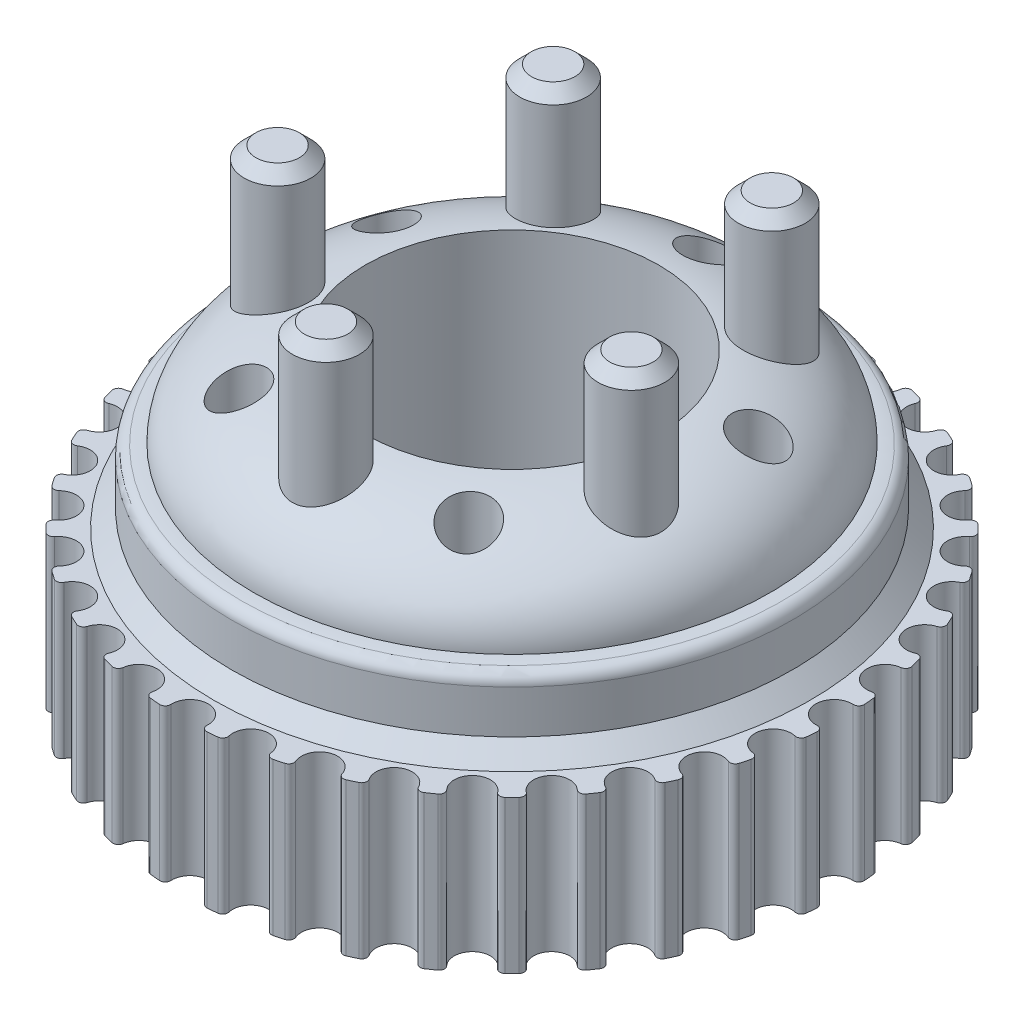
from build123d import *

# Parameters (mm, degrees)
SKIZZE1_R                       = 28.076389757
AUFSATZ_LINEAR_AUSTRAGEN1_DEPTH = 13
SCHNITT_LINEAR_AUSTRAGEN1_DEPTH = 42.779987117
KREISMUSTER1_COUNT              = 36
SKIZZE24_R                      = 12.5
HANGAR_HOLE_DEPTH               = 42.740895817
SKIZZE25_R                      = 2.1
MOUNTING_HOLES_DEPTH            = 42.740895817
MOUNTING_HOLES_DEPTH_BACK       = 42.740895817
SKIZZE28_R                      = 2.85
PINS_DEPTH                      = 10
PINS_DIRECTION_2_REACH          = 49.477
FASE2_SIZE                      = 1
SKIZZE29_R                      = 3.75
COUNTERSINKS_DEPTH              = 5
AUFSATZ_LINEAR_AUSTRAGEN6_DEPTH = 0.4
AUFSATZ_LINEAR_AUSTRAGEN7_DEPTH = 0.2
FASE3_SIZE                      = 1.5
SCHNITT_LINEAR_AUSTRAGEN7_DEPTH = 4.6
KREISMUSTER3_COUNT              = 5


with BuildPart() as part:
    # Skizze1 → Aufsatz-Linear austragen1 (new body)
    with BuildSketch(Plane(origin=(0, 0, 0), x_dir=(1, 0, 0), z_dir=(0, 1, 0))):
        with Locations(Location((0, 0, 0), (0, 0, 90))):
            Circle(SKIZZE1_R)
    extrude(amount=AUFSATZ_LINEAR_AUSTRAGEN1_DEPTH)

    # Zahnung → Schnitt-Linear austragen1 (cut, through all)
    with BuildSketch(Plane(origin=(0, 13, 0), x_dir=(1, 0, 0), z_dir=(0, 1, 0))):
        with BuildLine():
            ThreePointArc((-1.542894139, 27.524912022), (0, 25.892849757), (1.542894139, 27.524912022))
            ThreePointArc((1.542894139, 27.524912022), (1.677698107, 27.873850157), (2.028769929, 28.002995453))
            ThreePointArc((2.028769929, 28.002995453), (0, 28.076389757), (-2.028769929, 28.002995453))
            ThreePointArc((-2.028769929, 28.002995453), (-1.677698107, 27.873850157), (-1.542894139, 27.524912022))
        make_face()
    schnitt_linear_austragen1 = extrude(amount=-SCHNITT_LINEAR_AUSTRAGEN1_DEPTH, mode=Mode.SUBTRACT)

    # Kreismuster1: Schnitt-Linear austragen1 ×36 about axis
    kreismuster1_axis = Axis((0, 0, 0), (0, 1, 0))
    for i in range(1, KREISMUSTER1_COUNT):
        add(schnitt_linear_austragen1.rotate(kreismuster1_axis, i * 360 / KREISMUSTER1_COUNT), mode=Mode.SUBTRACT)

    # Skizze23 → Body (revolve)
    with BuildSketch(Plane(origin=(0, 0, 0), x_dir=(0, 0, -1), z_dir=(1, 0, 0))):
        with BuildLine():
            Line((-23.892849757, 13), (-23.892849757, 18.177651499))
            ThreePointArc((-23.892849757, 18.177651499), (-23.650534927, 18.830271743), (-23.041023393, 19.16661286))
            add(Edge.make_bspline(
                [(-23.041023393, 19.16661286), (-22.705496435, 19.216884035), (-22.359095546, 19.245823161), (-22, 19.25)],
                knots=[0.666203438, 0.666203438, 0.666203438, 0.666203438, 0.739788327, 0.739788327, 0.739788327, 0.739788327], degree=3))
            add(Edge.make_bspline(
                [(-22, 19.25), (-22, 22.881223738), (-18.269694005, 25.679215042), (-12.5, 26.184611956)],
                knots=[0, 0, 0, 0, 0.905796835, 0.905796835, 0.905796835, 0.905796835], degree=3, weights=[1, 0.823132166, 0.806470657, 0.950015471]))
            Line((-12.5, 26.184611956), (-12.5, 13))
            Line((-12.5, 13), (-23.892849757, 13))
        make_face()
    revolve(axis=Axis((0, 13, 0), (0, -1, 0)))

    # Skizze24 → Hangar hole (cut, through all)
    with BuildSketch(Plane(origin=(0, 13, 0), x_dir=(1, 0, 0), z_dir=(0, 1, 0))):
        with Locations(Location((0, 0, 0), (0, 0, 270))):
            Circle(SKIZZE24_R)
    extrude(amount=-HANGAR_HOLE_DEPTH, mode=Mode.SUBTRACT)

    # Skizze25 → Mounting holes (cut, two sides)
    with BuildSketch(Plane(origin=(0, 13, 0), x_dir=(1, 0, 0), z_dir=(0, 1, 0))) as mounting_holes_sk:
        with Locations(Location((0, 16.655, 0), (0, 0, 270))):
            Circle(SKIZZE25_R)
        with Locations(Location((15.839846279, 5.146678041, 0), (0, 0, 270))):
            Circle(SKIZZE25_R)
        with Locations(Location((9.789563377, -13.474178041, 0), (0, 0, 270))):
            Circle(SKIZZE25_R)
        with Locations(Location((-9.789563377, -13.474178041, 0), (0, 0, 270))):
            Circle(SKIZZE25_R)
        with Locations(Location((-15.839846279, 5.146678041, 0), (0, 0, 270))):
            Circle(SKIZZE25_R)
    extrude(amount=MOUNTING_HOLES_DEPTH, mode=Mode.SUBTRACT)
    extrude(mounting_holes_sk.sketch, amount=-MOUNTING_HOLES_DEPTH_BACK, mode=Mode.SUBTRACT)

    # Skizze28 → Pins (add)
    with BuildSketch(Plane(origin=(0, 26.184611956, 0), x_dir=(-1, 0, 0), z_dir=(0, -1, 0))):
        with Locations(Location((-9.316396249, 12.822919361, 0), (0, 0, 270))):
            Circle(SKIZZE28_R)
        with Locations(Location((9.316396249, 12.822919361, 0), (0, 0, 270))):
            Circle(SKIZZE28_R)
        with Locations(Location((15.074245783, -4.897919361, 0), (0, 0, 270))):
            Circle(SKIZZE28_R)
        with Locations(Location((0, -15.85, 0), (0, 0, 90))):
            Circle(SKIZZE28_R)
        with Locations(Location((-15.074245783, -4.897919361, 0), (0, 0, 270))):
            Circle(SKIZZE28_R)
    extrude(amount=-PINS_DEPTH)

    # Skizze28 → Pins direction 2 (add, up to next)
    with BuildSketch(Plane(origin=(0, 26.184611956, 0), x_dir=(-1, 0, 0), z_dir=(0, -1, 0)), mode=Mode.PRIVATE) as pins_direction_2_sk1:
        with Locations(Location((-9.316396249, 12.822919361, 0), (0, 0, 270))):
            Circle(SKIZZE28_R)
    pins_direction_2_tool1 = extrude(pins_direction_2_sk1.sketch, amount=PINS_DIRECTION_2_REACH, mode=Mode.PRIVATE) - part.part
    # Skizze28 → Pins direction 2 (add, up to next)
    with BuildSketch(Plane(origin=(0, 26.184611956, 0), x_dir=(-1, 0, 0), z_dir=(0, -1, 0)), mode=Mode.PRIVATE) as pins_direction_2_sk2:
        with Locations(Location((9.316396249, 12.822919361, 0), (0, 0, 270))):
            Circle(SKIZZE28_R)
    pins_direction_2_tool2 = extrude(pins_direction_2_sk2.sketch, amount=PINS_DIRECTION_2_REACH, mode=Mode.PRIVATE) - part.part
    # Skizze28 → Pins direction 2 (add, up to next)
    with BuildSketch(Plane(origin=(0, 26.184611956, 0), x_dir=(-1, 0, 0), z_dir=(0, -1, 0)), mode=Mode.PRIVATE) as pins_direction_2_sk3:
        with Locations(Location((15.074245783, -4.897919361, 0), (0, 0, 270))):
            Circle(SKIZZE28_R)
    pins_direction_2_tool3 = extrude(pins_direction_2_sk3.sketch, amount=PINS_DIRECTION_2_REACH, mode=Mode.PRIVATE) - part.part
    # Skizze28 → Pins direction 2 (add, up to next)
    with BuildSketch(Plane(origin=(0, 26.184611956, 0), x_dir=(-1, 0, 0), z_dir=(0, -1, 0)), mode=Mode.PRIVATE) as pins_direction_2_sk4:
        with Locations(Location((0, -15.85, 0), (0, 0, 90))):
            Circle(SKIZZE28_R)
    pins_direction_2_tool4 = extrude(pins_direction_2_sk4.sketch, amount=PINS_DIRECTION_2_REACH, mode=Mode.PRIVATE) - part.part
    # Skizze28 → Pins direction 2 (add, up to next)
    with BuildSketch(Plane(origin=(0, 26.184611956, 0), x_dir=(-1, 0, 0), z_dir=(0, -1, 0)), mode=Mode.PRIVATE) as pins_direction_2_sk5:
        with Locations(Location((-15.074245783, -4.897919361, 0), (0, 0, 270))):
            Circle(SKIZZE28_R)
    pins_direction_2_tool5 = extrude(pins_direction_2_sk5.sketch, amount=PINS_DIRECTION_2_REACH, mode=Mode.PRIVATE) - part.part
    add(pins_direction_2_tool1.solids().sort_by_distance((9.316396, 26.184612, -12.822919))[0])
    add(pins_direction_2_tool2.solids().sort_by_distance((-9.316396, 26.184612, -12.822919))[0])
    add(pins_direction_2_tool3.solids().sort_by_distance((-15.074246, 26.184612, 4.897919))[0])
    add(pins_direction_2_tool4.solids().sort_by_distance((0, 26.184612, 15.85))[0])
    add(pins_direction_2_tool5.solids().sort_by_distance((15.074246, 26.184612, 4.897919))[0])

    # Fase2
    fase2_edges = [part.edges().sort_by_distance(p)[0] for p in [
        (9.316396249, 36.184611956, -15.672919361),
        (-9.316396249, 36.184611956, -15.672919361),
        (-15.074245783, 36.184611956, 2.047919361),
        (0, 36.184611956, 18.7),
        (15.074245783, 36.184611956, 2.047919361),
    ]]
    chamfer(fase2_edges, length=FASE2_SIZE)

    # Skizze29 → Countersinks (cut)
    with BuildSketch(Plane.XZ):
        with Locations(Location((-9.789563377, 13.474178041, 0), (0, 0, 270))):
            Circle(SKIZZE29_R)
        with Locations(Location((9.789563377, 13.474178041, 0), (0, 0, 270))):
            Circle(SKIZZE29_R)
        with Locations(Location((15.839846279, -5.146678041, 0), (0, 0, 270))):
            Circle(SKIZZE29_R)
        with Locations(Location((0, -16.655, 0), (0, 0, 270))):
            Circle(SKIZZE29_R)
        with Locations(Location((-15.839846279, -5.146678041, 0), (0, 0, 270))):
            Circle(SKIZZE29_R)
    extrude(amount=-COUNTERSINKS_DEPTH, mode=Mode.SUBTRACT)

    # Skizze32 → Aufsatz-Linear austragen6 (add)
    with BuildSketch(Plane.XZ.offset(-5)):
        with BuildLine():
            Line((7e-09, -14.555), (2.1, -14.555))
            Line((2.1, -14.555), (3.106847277, -14.555))
            ThreePointArc((3.106847277, -14.555), (0, -12.905), (-3.106847277, -14.555))
            Line((-3.106847277, -14.555), (-2.1, -14.555))
            Line((-2.1, -14.555), (7e-09, -14.555))
        make_face()
        with BuildLine():
            Line((3.106847277, -18.755), (2.1, -18.755))
            Line((2.1, -18.755), (0, -18.755))
            Line((0, -18.755), (-2.1, -18.755))
            Line((-2.1, -18.755), (-3.106847277, -18.755))
            ThreePointArc((-3.106847277, -18.755), (0, -20.405), (3.106847277, -18.755))
        make_face()
        with BuildLine():
            Line((-17.939846279, -5.146678041), (-17.939846279, -3.046678041))
            Line((-17.939846279, -3.046678041), (-17.939846279, -2.039830765))
            ThreePointArc((-17.939846279, -2.039830765), (-19.589846279, -5.146678041), (-17.939846279, -8.253525318))
            Line((-17.939846279, -8.253525318), (-17.939846279, -7.246678041))
            Line((-17.939846279, -7.246678041), (-17.939846279, -5.146678041))
        make_face()
        with BuildLine():
            Line((-13.739846279, -2.039830765), (-13.739846279, -3.046678041))
            Line((-13.739846279, -3.046678041), (-13.739846279, -5.146678041))
            Line((-13.739846279, -5.146678041), (-13.739846279, -7.246678041))
            Line((-13.739846279, -7.246678041), (-13.739846279, -8.253525318))
            ThreePointArc((-13.739846279, -8.253525318), (-12.527935954, -6.905583951), (-12.089846279, -5.146678041))
            ThreePointArc((-12.089846279, -5.146678041), (-12.527935954, -3.387772131), (-13.739846279, -2.039830765))
        make_face()
        with BuildLine():
            Line((-12.896410654, 15.574178041), (-11.889563377, 15.574178041))
            Line((-11.889563377, 15.574178041), (-9.789563377, 15.574178041))
            Line((-9.789563377, 15.574178041), (-7.689563377, 15.574178041))
            Line((-7.689563377, 15.574178041), (-6.6827161, 15.574178041))
            ThreePointArc((-6.6827161, 15.574178041), (-9.789563377, 17.224178041), (-12.896410654, 15.574178041))
        make_face()
        with BuildLine():
            Line((-9.789563377, 11.374178041), (-11.889563377, 11.374178041))
            Line((-11.889563377, 11.374178041), (-12.896410654, 11.374178041))
            ThreePointArc((-12.896410654, 11.374178041), (-9.789563377, 9.724178041), (-6.6827161, 11.374178041))
            Line((-6.6827161, 11.374178041), (-7.689563377, 11.374178041))
            Line((-7.689563377, 11.374178041), (-9.789563377, 11.374178041))
        make_face()
        with BuildLine():
            Line((6.6827161, 15.574178041), (7.689563377, 15.574178041))
            Line((7.689563377, 15.574178041), (9.789563377, 15.574178041))
            Line((9.789563377, 15.574178041), (11.889563377, 15.574178041))
            Line((11.889563377, 15.574178041), (12.896410654, 15.574178041))
            ThreePointArc((12.896410654, 15.574178041), (9.789563377, 17.224178041), (6.6827161, 15.574178041))
        make_face()
        with BuildLine():
            Line((9.789563377, 11.374178041), (7.689563377, 11.374178041))
            Line((7.689563377, 11.374178041), (6.6827161, 11.374178041))
            ThreePointArc((6.6827161, 11.374178041), (9.789563377, 9.724178041), (12.896410654, 11.374178041))
            Line((12.896410654, 11.374178041), (11.889563377, 11.374178041))
            Line((11.889563377, 11.374178041), (9.789563377, 11.374178041))
        make_face()
        with BuildLine():
            Line((17.939846279, -2.039830765), (17.939846279, -3.046678041))
            Line((17.939846279, -3.046678041), (17.939846279, -5.146678041))
            Line((17.939846279, -5.146678041), (17.939846279, -7.246678041))
            Line((17.939846279, -7.246678041), (17.939846279, -8.253525318))
            ThreePointArc((17.939846279, -8.253525318), (19.151756604, -6.905583951), (19.589846279, -5.146678041))
            ThreePointArc((19.589846279, -5.146678041), (19.151756604, -3.387772131), (17.939846279, -2.039830765))
        make_face()
        with BuildLine():
            Line((13.739846279, -5.146678041), (13.739846279, -3.046678041))
            Line((13.739846279, -3.046678041), (13.739846279, -2.039830765))
            ThreePointArc((13.739846279, -2.039830765), (12.089846279, -5.146678041), (13.739846279, -8.253525318))
            Line((13.739846279, -8.253525318), (13.739846279, -7.246678041))
            Line((13.739846279, -7.246678041), (13.739846279, -5.146678041))
        make_face()
    extrude(amount=AUFSATZ_LINEAR_AUSTRAGEN6_DEPTH)

    # Skizze32_3 → Aufsatz-Linear austragen7 (add)
    with BuildSketch(Plane.XZ.offset(-5)):
        with BuildLine():
            Line((-3.106847277, -18.755), (-2.1, -18.755))
            Line((-2.1, -18.755), (-2.1, -16.655))
            Line((-2.1, -16.655), (-2.1, -14.555))
            Line((-2.1, -14.555), (-3.106847277, -14.555))
            ThreePointArc((-3.106847277, -14.555), (-3.75, -16.655), (-3.106847277, -18.755))
        make_face()
        with BuildLine():
            Line((2.1, -16.655), (2.1, -18.755))
            Line((2.1, -18.755), (3.106847277, -18.755))
            ThreePointArc((3.106847277, -18.755), (3.585608546, -17.753139953), (3.75, -16.655))
            ThreePointArc((3.75, -16.655), (3.585608546, -15.556860047), (3.106847277, -14.555))
            Line((3.106847277, -14.555), (2.1, -14.555))
            Line((2.1, -14.555), (2.1, -16.655))
        make_face()
        with BuildLine():
            Line((-12.896410654, 11.374178041), (-11.889563377, 11.374178041))
            Line((-11.889563377, 11.374178041), (-11.889563377, 13.474178041))
            Line((-11.889563377, 13.474178041), (-11.889563377, 15.574178041))
            Line((-11.889563377, 15.574178041), (-12.896410654, 15.574178041))
            ThreePointArc((-12.896410654, 15.574178041), (-13.539563377, 13.474178041), (-12.896410654, 11.374178041))
        make_face()
        with BuildLine():
            Line((-7.689563377, 13.474178041), (-7.689563377, 11.374178041))
            Line((-7.689563377, 11.374178041), (-6.6827161, 11.374178041))
            ThreePointArc((-6.6827161, 11.374178041), (-6.203954831, 12.376038088), (-6.039563377, 13.474178041))
            ThreePointArc((-6.039563377, 13.474178041), (-6.203954831, 14.572317994), (-6.6827161, 15.574178041))
            Line((-6.6827161, 15.574178041), (-7.689563377, 15.574178041))
            Line((-7.689563377, 15.574178041), (-7.689563377, 13.474178041))
        make_face()
        with BuildLine():
            Line((7.689563377, 13.474178041), (7.689563377, 15.574178041))
            Line((7.689563377, 15.574178041), (6.6827161, 15.574178041))
            ThreePointArc((6.6827161, 15.574178041), (6.039563377, 13.474178041), (6.6827161, 11.374178041))
            Line((6.6827161, 11.374178041), (7.689563377, 11.374178041))
            Line((7.689563377, 11.374178041), (7.689563377, 13.474178041))
        make_face()
        with BuildLine():
            Line((12.896410654, 15.574178041), (11.889563377, 15.574178041))
            Line((11.889563377, 15.574178041), (11.889563377, 13.474178041))
            Line((11.889563377, 13.474178041), (11.889563377, 11.374178041))
            Line((11.889563377, 11.374178041), (12.896410654, 11.374178041))
            ThreePointArc((12.896410654, 11.374178041), (13.375171923, 12.376038088), (13.539563377, 13.474178041))
            ThreePointArc((13.539563377, 13.474178041), (13.375171923, 14.572317994), (12.896410654, 15.574178041))
        make_face()
        with BuildLine():
            Line((13.739846279, -2.039830765), (13.739846279, -3.046678041))
            Line((13.739846279, -3.046678041), (15.839846279, -3.046678041))
            Line((15.839846279, -3.046678041), (17.939846279, -3.046678041))
            Line((17.939846279, -3.046678041), (17.939846279, -2.039830765))
            ThreePointArc((17.939846279, -2.039830765), (15.839846279, -1.396678041), (13.739846279, -2.039830765))
        make_face()
        with BuildLine():
            Line((15.839846286, -7.246678041), (13.739846279, -7.246678041))
            Line((13.739846279, -7.246678041), (13.739846279, -8.253525318))
            ThreePointArc((13.739846279, -8.253525318), (15.839846279, -8.896678041), (17.939846279, -8.253525318))
            Line((17.939846279, -8.253525318), (17.939846279, -7.246678041))
            Line((17.939846279, -7.246678041), (15.839846286, -7.246678041))
        make_face()
        with BuildLine():
            Line((-17.939846279, -2.039830765), (-17.939846279, -3.046678041))
            Line((-17.939846279, -3.046678041), (-15.839846279, -3.046678041))
            Line((-15.839846279, -3.046678041), (-13.739846279, -3.046678041))
            Line((-13.739846279, -3.046678041), (-13.739846279, -2.039830765))
            ThreePointArc((-13.739846279, -2.039830765), (-15.839846279, -1.396678041), (-17.939846279, -2.039830765))
        make_face()
        with BuildLine():
            Line((-15.839846279, -7.246678041), (-17.939846279, -7.246678041))
            Line((-17.939846279, -7.246678041), (-17.939846279, -8.253525318))
            ThreePointArc((-17.939846279, -8.253525318), (-15.839846279, -8.896678041), (-13.739846279, -8.253525318))
            Line((-13.739846279, -8.253525318), (-13.739846279, -7.246678041))
            Line((-13.739846279, -7.246678041), (-15.839846279, -7.246678041))
        make_face()
    extrude(amount=AUFSATZ_LINEAR_AUSTRAGEN7_DEPTH)

    # Fase3
    fase3_edges = [part.edges().sort_by_distance(p)[0] for p in [
        (0, 13, -23.892849757),
    ]]
    chamfer(fase3_edges, length=FASE3_SIZE)

    # Skizze33 → Schnitt-Linear austragen7 (cut)
    with BuildSketch(Plane.XZ):
        Polygon((0, -12.364744303), (-1.009497586, -13.043433218), (1.009497586, -13.043433218), align=None)
    schnitt_linear_austragen7 = extrude(amount=-SCHNITT_LINEAR_AUSTRAGEN7_DEPTH, mode=Mode.SUBTRACT)

    # Kreismuster3: Schnitt-Linear austragen7 ×5 about axis
    kreismuster3_axis = Axis((0, 0, 0), (0, 1, 0))
    for i in range(1, KREISMUSTER3_COUNT):
        add(schnitt_linear_austragen7.rotate(kreismuster3_axis, i * 360 / KREISMUSTER3_COUNT), mode=Mode.SUBTRACT)


solid = part.part
